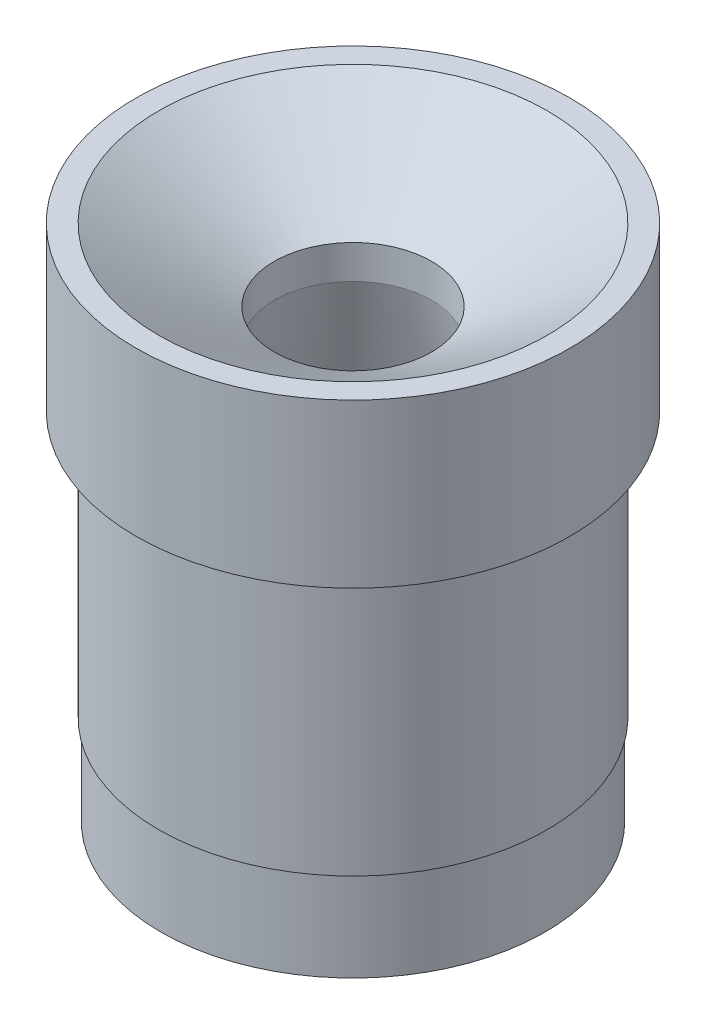
from build123d import *


with BuildPart() as part:
    # Sketch4 → Revolve1 (revolve)
    with BuildSketch(Plane(origin=(0, 0, 0), x_dir=(0, 0, -1), z_dir=(1, 0, 0))):
        Polygon((24.511, 0), (24.511, 18.415), (21.971, 18.415), (8.89, 10.229390231), (8.89, 6.419390231), (20.066, -40.132), (21.717, -40.132), (21.717, -29.972), (21.971, -29.972), (21.971, 0), align=None)
    revolve(axis=Axis((0, 21.55825, 0), (0, -1, 0)))


solid = part.part
